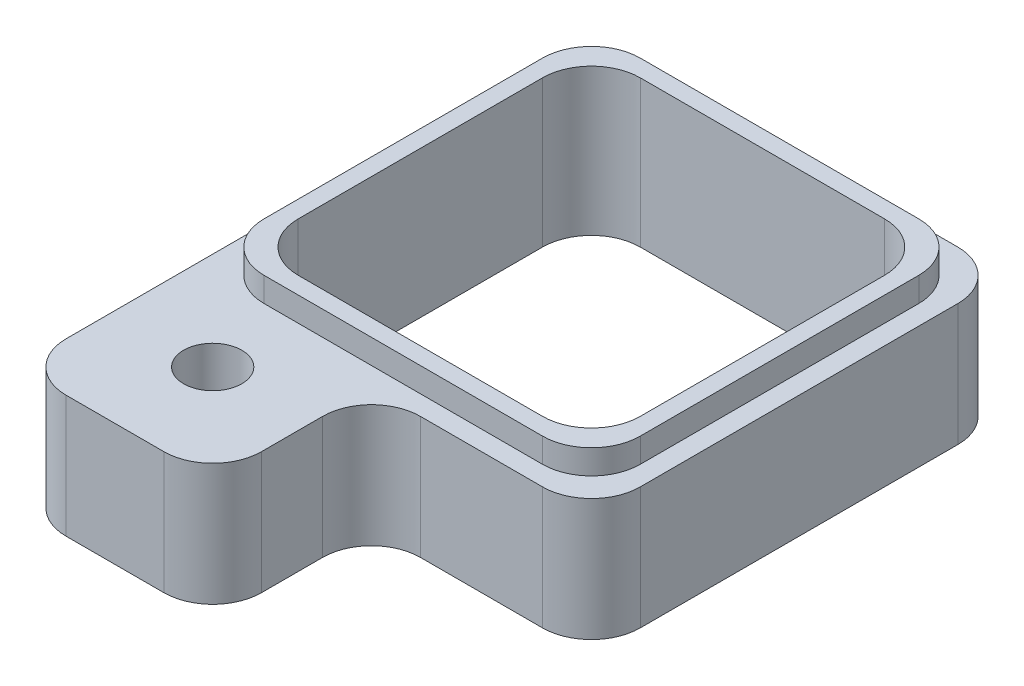
from build123d import *

# Parameters (mm, degrees)
SKETCH1_W             = 8.5
SKETCH1_H             = 8.5
EXTRUDE1_DEPTH        = 2.5
SKETCH15_W            = 7.7
SKETCH15_H            = 7.7
EXTRUDE8_DEPTH        = 0.5
SKETCH3_W             = 4
SKETCH3_H             = 2.5
EXTRUDE3_DEPTH        = 3.25
SKETCH2_W             = 7
SKETCH2_H             = 7
EXTRUDE2_DEPTH        = 1.5
EXTRUDE2_DEPTH_BACK   = 3.5
F_0_80_TAPPED_HOLE1_D = 1.19126
SKETCH11_W            = 2
SKETCH11_H            = 1
EXTRUDE5_DEPTH        = 1.5
FILLET1_R             = 1


with BuildPart() as part:
    # Sketch1 → Extrude1 (new body)
    with BuildSketch(Plane(origin=(0, 0, 0), x_dir=(1, 0, 0), z_dir=(0, 1, 0))):
        Rectangle(SKETCH1_W, SKETCH1_H)
    extrude(amount=EXTRUDE1_DEPTH)

    # Sketch15 → Extrude8 (add)
    with BuildSketch(Plane(origin=(0, 2.5, 0), x_dir=(1, 0, 0), z_dir=(0, 1, 0))):
        Rectangle(SKETCH15_W, SKETCH15_H)
    extrude(amount=EXTRUDE8_DEPTH)

    # Sketch3 → Extrude3 (add)
    with BuildSketch(Plane.XY.offset(4.25)):
        with Locations((-2.25, 1.25)):
            Rectangle(SKETCH3_W, SKETCH3_H)
    extrude(amount=EXTRUDE3_DEPTH)

    # Sketch2 → Extrude2 (cut, two sides)
    with BuildSketch(Plane(origin=(0, 2.5, 0), x_dir=(1, 0, 0), z_dir=(0, 1, 0))) as extrude2_sk:
        Rectangle(SKETCH2_W, SKETCH2_H)
    extrude(amount=EXTRUDE2_DEPTH, mode=Mode.SUBTRACT)
    extrude(extrude2_sk.sketch, amount=-EXTRUDE2_DEPTH_BACK, mode=Mode.SUBTRACT)

    # #0-80 Tapped Hole1 (through all)
    with Locations(Plane(origin=(-2.25, 2.5, 5.5), x_dir=(0, 0, 1), z_dir=(0, 1, 0))):
        with Locations((0, 0)):
            Hole(F_0_80_TAPPED_HOLE1_D / 2)

    # Sketch11 → Extrude5 (add)
    with BuildSketch(Plane(origin=(0, 0, -4.25), x_dir=(-1, 0, 0), z_dir=(0, 0, -1))):
        with Locations((-0.42960296, 0.5)):
            Rectangle(SKETCH11_W, SKETCH11_H)
    extrude(amount=EXTRUDE5_DEPTH)

    # Fillet1
    fillet1_edges = [part.edges().sort_by_distance(p)[0] for p in [
        (3.5, 1.5, -3.5),
        (-3.5, 1.5, -3.5),
        (-3.5, 1.5, 3.5),
        (3.5, 1.5, 3.5),
        (-4.25, 1.25, 7.5),
        (-0.25, 1.25, 7.5),
        (-0.25, 1.25, 4.25),
        (4.25, 1.25, 4.25),
        (4.25, 1.25, -4.25),
        (-4.25, 1.25, -4.25),
        (-3.85, 2.75, 3.85),
        (-3.85, 2.75, -3.85),
        (3.85, 2.75, -3.85),
        (3.85, 2.75, 3.85),
    ]]
    fillet(fillet1_edges, radius=FILLET1_R)


solid = part.part
